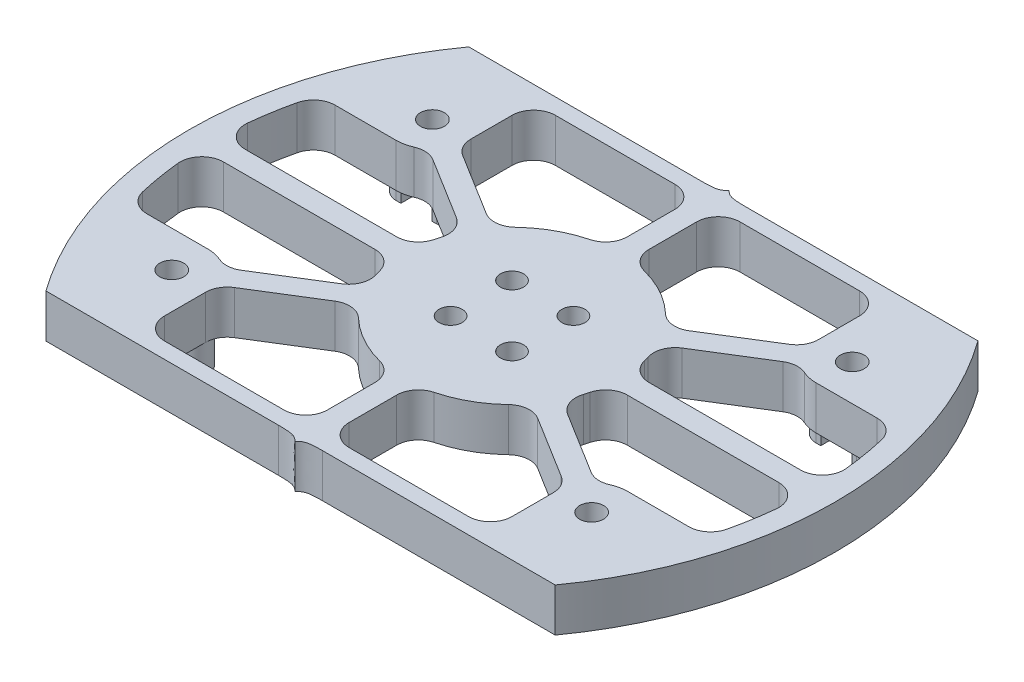
from build123d import *

# Parameters (mm, degrees)
EXTRUDE_1_DEPTH             = 6
CUT_EXTRUDE_1_DEPTH         = 7
SKETCH_3_R                  = 5
EXTRUDE_2_DEPTH             = 6
EXTRUDE_2_2_DEPTH           = 6
EXTRUDE_2_3_DEPTH           = 6
EXTRUDE_2_4_DEPTH           = 6
SKETCH_3_R_2                = 15
EXTRUDE_2_5_DEPTH           = 6
EXTRUDE_3_DEPTH             = 6
EXTRUDE_4_DEPTH             = 6
FILLET_1_R                  = 3
CUT_EXTRUDE_2_DEPTH         = 7.0000001
M4X0_71_D                   = 3.3
EXTRUDE_5_DEPTH             = 4
M4X0_72_D                   = 3.3
HOLE_WIZARD_M31_D           = 3.2
HOLE_WIZARD_M31_CBORE_D     = 6.5
HOLE_WIZARD_M31_CBORE_DEPTH = 3
SKETCH_15_W                 = 4.3
SKETCH_15_H                 = 40.4
CUT_EXTRUDE_3_DEPTH         = 4


with BuildPart() as part:
    # Эскиз1 → Бобышка-Вытянуть1 (new body)
    with BuildSketch(Plane(origin=(0, 0, 0), x_dir=(1, 0, 0), z_dir=(0, 1, 0))):
        with BuildLine():
            Line((79.165543512, 0), (10, 0))
            ThreePointArc((10, 0), (0, 30), (10, 60))
            Line((10, 60), (79.165543512, 60))
            ThreePointArc((79.165543512, 60), (89.165543512, 30), (79.165543512, 0))
        make_face()
    extrude(amount=EXTRUDE_1_DEPTH)

    # Эскиз2 → Вырез-Вытянуть1 (cut, through all)
    with BuildSketch(Plane(origin=(0, 6, 0), x_dir=(1, 0, 0), z_dir=(0, 1, 0))):
        with BuildLine():
            Line((11.529231877, 3), (77.636311635, 3))
            ThreePointArc((77.636311635, 3), (86.165543512, 30), (77.636311635, 57))
            Line((77.636311635, 57), (11.529231877, 57))
            ThreePointArc((11.529231877, 57), (3, 30), (11.529231877, 3))
        make_face()
    extrude(amount=-CUT_EXTRUDE_1_DEPTH, mode=Mode.SUBTRACT)



with BuildPart() as body_2:
    # Эскиз3 → Бобышка-Вытянуть2 (new body, through all)
    with BuildSketch(Plane(origin=(0, 6, 0), x_dir=(1, 0, 0), z_dir=(0, 1, 0))):
        with Locations((15.582771756, 48)):
            Circle(SKETCH_3_R)
    extrude(amount=-EXTRUDE_2_DEPTH)


with BuildPart() as body_3:
    # Эскиз3 → Extrude 2 2 (new body, through all)
    with BuildSketch(Plane(origin=(0, 6, 0), x_dir=(1, 0, 0), z_dir=(0, 1, 0))):
        with Locations((73.582771756, 48)):
            Circle(SKETCH_3_R)
    extrude(amount=-EXTRUDE_2_2_DEPTH)


with BuildPart() as body_4:
    # Эскиз3 → Extrude 2 3 (new body, through all)
    with BuildSketch(Plane(origin=(0, 6, 0), x_dir=(1, 0, 0), z_dir=(0, 1, 0))):
        with Locations((73.582771756, 12)):
            Circle(SKETCH_3_R)
    extrude(amount=-EXTRUDE_2_3_DEPTH)


with BuildPart() as body_5:
    # Эскиз3 → Extrude 2 4 (new body, through all)
    with BuildSketch(Plane(origin=(0, 6, 0), x_dir=(1, 0, 0), z_dir=(0, 1, 0))):
        with Locations((15.582771756, 12)):
            Circle(SKETCH_3_R)
    extrude(amount=-EXTRUDE_2_4_DEPTH)


with BuildPart() as body_6:
    # Эскиз3 → Extrude 2 5 (new body, through all)
    with BuildSketch(Plane(origin=(0, 6, 0), x_dir=(1, 0, 0), z_dir=(0, 1, 0))):
        with Locations((44.582771756, 30)):
            Circle(SKETCH_3_R_2)
    extrude(amount=-EXTRUDE_2_5_DEPTH)


with BuildPart() as part_1:
    add(part.part)

    add(body_2.part)  # Бобышка-Вытянуть3 merges body 2

    add(body_3.part)  # Бобышка-Вытянуть3 merges body 3

    add(body_4.part)  # Бобышка-Вытянуть3 merges body 4

    add(body_5.part)  # Бобышка-Вытянуть3 merges body 5

    add(body_6.part)  # Бобышка-Вытянуть3 merges body 6
    # Эскиз4 → Бобышка-Вытянуть3 (add, through all)
    with BuildSketch(Plane(origin=(0, 6, 0), x_dir=(1, 0, 0), z_dir=(0, 1, 0))):
        with BuildLine():
            ThreePointArc((31.111008092, 36.596331085), (31.838169263, 37.910442927), (32.693096677, 39.145251583))
            Line((32.693096677, 39.145251583), (20.426341357, 46.759099713))
            ThreePointArc((20.426341357, 46.759099713), (19.830972587, 45.363185691), (18.844252772, 44.210179215))
            Line((18.844252772, 44.210179215), (31.111008092, 36.596331085))
        make_face()
        with BuildLine():
            ThreePointArc((43.082771756, 44.924811557), (44.582771756, 45), (46.082771756, 44.924811557))
            Line((46.082771756, 44.924811557), (46.082771756, 57))
            Line((46.082771756, 57), (43.082771756, 57))
            Line((43.082771756, 57), (43.082771756, 44.924811557))
        make_face()
        with BuildLine():
            Line((68.739202155, 46.759099713), (56.472446835, 39.145251583))
            ThreePointArc((56.472446835, 39.145251583), (57.327374249, 37.910442927), (58.05453542, 36.596331085))
            Line((58.05453542, 36.596331085), (70.32129074, 44.210179215))
            ThreePointArc((70.32129074, 44.210179215), (69.334570925, 45.363185691), (68.739202155, 46.759099713))
        make_face()
        with BuildLine():
            Line((86.141601244, 31.5), (59.507583313, 31.5))
            ThreePointArc((59.507583313, 31.5), (59.563962853, 30.750941626), (59.582771756, 30))
            ThreePointArc((59.582771756, 30), (59.563962853, 29.249058374), (59.507583313, 28.5))
            Line((59.507583313, 28.5), (86.141601244, 28.5))
            Line((86.141601244, 28.5), (86.672716069, 28.5))
            Line((86.672716069, 28.5), (86.672716069, 31.5))
            Line((86.672716069, 31.5), (86.141601244, 31.5))
        make_face()
        with BuildLine():
            Line((70.32129074, 15.789820785), (58.05453542, 23.403668915))
            ThreePointArc((58.05453542, 23.403668915), (57.327374249, 22.089557073), (56.472446835, 20.854748417))
            Line((56.472446835, 20.854748417), (68.739202155, 13.240900287))
            ThreePointArc((68.739202155, 13.240900287), (69.334570925, 14.636814309), (70.32129074, 15.789820785))
        make_face()
        with BuildLine():
            Line((46.082771756, 3), (46.082771756, 15.075188443))
            ThreePointArc((46.082771756, 15.075188443), (44.582771756, 15), (43.082771756, 15.075188443))
            Line((43.082771756, 15.075188443), (43.082771756, 3))
            Line((43.082771756, 3), (46.082771756, 3))
        make_face()
        with BuildLine():
            ThreePointArc((32.693096677, 20.854748417), (31.838169263, 22.089557073), (31.111008092, 23.403668915))
            Line((31.111008092, 23.403668915), (18.844252772, 15.789820785))
            ThreePointArc((18.844252772, 15.789820785), (19.830972587, 14.636814309), (20.426341357, 13.240900287))
            Line((20.426341357, 13.240900287), (32.693096677, 20.854748417))
        make_face()
        with BuildLine():
            ThreePointArc((29.657960199, 28.5), (29.582771756, 30), (29.657960199, 31.5))
            Line((29.657960199, 31.5), (3.023942268, 31.5))
            Line((3.023942268, 31.5), (2.402125711, 31.5))
            Line((2.402125711, 31.5), (2.402125711, 28.5))
            Line((2.402125711, 28.5), (3.023942268, 28.5))
            Line((3.023942268, 28.5), (29.657960199, 28.5))
        make_face()
    extrude(amount=-EXTRUDE_3_DEPTH)

    # Эскиз5 → Бобышка-Вытянуть4 (add, through all)
    with BuildSketch(Plane.XZ):
        with BuildLine():
            Line((20.582771756, -3), (20.582771756, -12))
            ThreePointArc((20.582771756, -12), (12.04723785, -8.464466094), (15.582771756, -17))
            Line((15.582771756, -17), (4.833640837, -17))
            ThreePointArc((4.833640837, -17), (7.599619516, -9.721742312), (11.529231877, -3))
            Line((11.529231877, -3), (20.582771756, -3))
        make_face()
        with BuildLine():
            Line((84.331902675, -17), (73.582771756, -17))
            ThreePointArc((73.582771756, -17), (77.118305662, -8.464466094), (68.582771756, -12))
            Line((68.582771756, -12), (68.582771756, -3))
            Line((68.582771756, -3), (77.636311635, -3))
            ThreePointArc((77.636311635, -3), (81.565923996, -9.721742312), (84.331902675, -17))
        make_face()
        with BuildLine():
            Line((77.636311635, -57), (68.582771756, -57))
            Line((68.582771756, -57), (68.582771756, -48))
            ThreePointArc((68.582771756, -48), (77.118305662, -51.535533906), (73.582771756, -43))
            Line((73.582771756, -43), (84.331902675, -43))
            ThreePointArc((84.331902675, -43), (81.565923996, -50.278257688), (77.636311635, -57))
        make_face()
        with BuildLine():
            Line((11.529231877, -57), (20.582771756, -57))
            Line((20.582771756, -57), (20.582771756, -48))
            ThreePointArc((20.582771756, -48), (12.04723785, -51.535533906), (15.582771756, -43))
            Line((15.582771756, -43), (4.833640837, -43))
            ThreePointArc((4.833640837, -43), (7.599619516, -50.278257688), (11.529231877, -57))
        make_face()
    extrude(amount=-EXTRUDE_4_DEPTH)

    # Скругление1
    fillet_1_edges = [part_1.edges().sort_by_distance(p)[0] for p in [
        (70.32129074, 3, -44.210179215),
        (58.05453542, 3, -36.596331085),
        (59.507583313, 3, -31.5),
        (59.507583313, 3, -28.5),
        (58.05453542, 3, -23.403668915),
        (70.32129074, 3, -15.789820785),
        (84.331902675, 3, -17),
        (86.141601244, 3, -28.5),
        (86.141601244, 3, -31.5),
        (84.331902675, 3, -43),
        (56.472446835, 3, -39.145251583),
        (46.082771756, 3, -44.924811557),
        (46.082771756, 3, -57),
        (68.582771756, 3, -57),
        (68.739202155, 3, -46.759099713),
        (43.082771756, 3, -44.924811557),
        (43.082771756, 3, -57),
        (20.582771756, 3, -57),
        (32.693096677, 3, -39.145251583),
        (20.426341357, 3, -46.759099713),
        (31.111008092, 3, -36.596331085),
        (18.844252772, 3, -44.210179215),
        (4.833640837, 3, -43),
        (3.023942268, 3, -31.5),
        (29.657960199, 3, -31.5),
        (29.657960199, 3, -28.5),
        (3.023942268, 3, -28.5),
        (4.833640837, 3, -17),
        (18.844252772, 3, -15.789820785),
        (31.111008092, 3, -23.403668915),
        (43.082771756, 3, -3),
        (20.582771756, 3, -3),
        (20.426341357, 3, -13.240900287),
        (32.693096677, 3, -20.854748417),
        (43.082771756, 3, -15.075188443),
        (56.472446835, 3, -20.854748417),
        (46.082771756, 3, -15.075188443),
        (46.082771756, 3, -3),
        (68.582771756, 3, -3),
        (68.739202155, 3, -13.240900287),
    ]]
    fillet(fillet_1_edges, radius=FILLET_1_R)

    # Эскиз8 → Вырез-Вытянуть2 (cut, through all)
    with BuildSketch(Plane.XZ):
        with BuildLine():
            ThreePointArc((10, 0), (9.704173203, -0.398541543), (9.412317139, -0.8))
            Line((9.412317139, -0.8), (41.52777131, -0.8))
            add(Edge.make_bspline(
                [(44.582771756, 0), (43.959141321, -0.703584088), (43.274165183, -0.8), (41.52777131, -0.8)],
                knots=[0, 0, 0, 0, 1, 1, 1, 1], degree=3))
            Line((44.582771756, 0), (10, 0))
        make_face()
        with BuildLine():
            Line((79.165543512, 0), (44.582771756, 0))
            add(Edge.make_bspline(
                [(44.582771756, 0), (45.206402191, -0.703584088), (45.891378329, -0.8), (47.637772202, -0.8)],
                knots=[0, 0, 0, 0, 1, 1, 1, 1], degree=3))
            Line((47.637772202, -0.8), (79.753226373, -0.8))
            ThreePointArc((79.753226373, -0.8), (79.461370308, -0.398541543), (79.165543512, 0))
        make_face()
        with BuildLine():
            Line((10, -60), (44.582771756, -60))
            add(Edge.make_bspline(
                [(44.582771756, -60), (43.959141321, -59.296415912), (43.274165183, -59.2), (41.52777131, -59.2)],
                knots=[0, 0, 0, 0, 1, 1, 1, 1], degree=3))
            Line((41.52777131, -59.2), (9.412317139, -59.2))
            ThreePointArc((9.412317139, -59.2), (9.704173203, -59.601458457), (10, -60))
        make_face()
        with BuildLine():
            Line((44.582771756, -60), (79.165543512, -60))
            ThreePointArc((79.165543512, -60), (79.461370308, -59.601458457), (79.753226373, -59.2))
            Line((79.753226373, -59.2), (47.637772202, -59.2))
            add(Edge.make_bspline(
                [(44.582771756, -60), (45.206402191, -59.296415912), (45.891378329, -59.2), (47.637772202, -59.2)],
                knots=[0, 0, 0, 0, 1, 1, 1, 1], degree=3))
        make_face()
    extrude(amount=-CUT_EXTRUDE_2_DEPTH, mode=Mode.SUBTRACT)

    # Отверстие обработанное метчиком M4x0.71 (through all)
    with Locations(Plane(origin=(0, 0, 0), x_dir=(-1, 0, 0), z_dir=(0, -1, 0))):
        with Locations((-15.582771756, 12), (-73.582771756, 12), (-73.582771756, 48), (-15.582771756, 48)):
            Hole(M4X0_71_D / 2)

    # Эскиз9 → Бобышка-Вытянуть5 (add)
    with BuildSketch(Plane(origin=(0, 0, 0), x_dir=(1, 0, 0), z_dir=(0, 1, 0))):
        with BuildLine():
            Line((12.782771348, 50.2), (18.382772164, 50.2))
            ThreePointArc((18.382772164, 50.2), (20.582771756, 48), (18.382772164, 45.8))
            Line((18.382772164, 45.8), (12.782771348, 45.8))
            ThreePointArc((12.782771348, 45.8), (10.582771756, 48), (12.782771348, 50.2))
        make_face()
        with BuildLine():
            Line((12.782771348, 14.2), (18.382772164, 14.2))
            ThreePointArc((18.382772164, 14.2), (20.582771756, 12), (18.382772164, 9.8))
            Line((18.382772164, 9.8), (12.782771348, 9.8))
            ThreePointArc((12.782771348, 9.8), (10.582771756, 12), (12.782771348, 14.2))
        make_face()
        with BuildLine():
            Line((76.382772164, 45.8), (70.782771348, 45.8))
            ThreePointArc((70.782771348, 45.8), (68.582771756, 48), (70.782771348, 50.2))
            Line((70.782771348, 50.2), (76.382772164, 50.2))
            ThreePointArc((76.382772164, 50.2), (78.582771756, 48), (76.382772164, 45.8))
        make_face()
        with BuildLine():
            Line((76.382772164, 9.8), (70.782771348, 9.8))
            ThreePointArc((70.782771348, 9.8), (68.582771756, 12), (70.782771348, 14.2))
            Line((70.782771348, 14.2), (76.382772164, 14.2))
            ThreePointArc((76.382772164, 14.2), (78.582771756, 12), (76.382772164, 9.8))
        make_face()
    extrude(amount=-EXTRUDE_5_DEPTH)

    # Отверстие обработанное метчиком M4x0.72 (through all)
    with Locations(Plane(origin=(0, -4, 0), x_dir=(-1, 0, 0), z_dir=(0, -1, 0))):
        with Locations((-73.582771756, 48), (-15.582771756, 48), (-15.582771756, 12), (-73.582771756, 12)):
            Hole(M4X0_72_D / 2)

    # Цековка для винта с внутренним шестигранником M31 (through all)
    with Locations(Plane(origin=(0, 0, 0), x_dir=(-1, 0, 0), z_dir=(0, -1, 0))):
        with Locations((-40.340131069, 25.757359313), (-48.825412443, 25.757359313), (-48.825412443, 34.242640687), (-40.340131069, 34.242640687)):
            CounterBoreHole(HOLE_WIZARD_M31_D / 2, HOLE_WIZARD_M31_CBORE_D / 2, HOLE_WIZARD_M31_CBORE_DEPTH)

    # Эскиз15 → Вырез-Вытянуть3 (cut)
    with BuildSketch(Plane.XZ.offset(4)):
        with Locations((15.582771756, -30)):
            Rectangle(SKETCH_15_W, SKETCH_15_H)
        with Locations((73.582771756, -30)):
            Rectangle(SKETCH_15_W, SKETCH_15_H)
    extrude(amount=-CUT_EXTRUDE_3_DEPTH, mode=Mode.SUBTRACT)


solid = part_1.part
